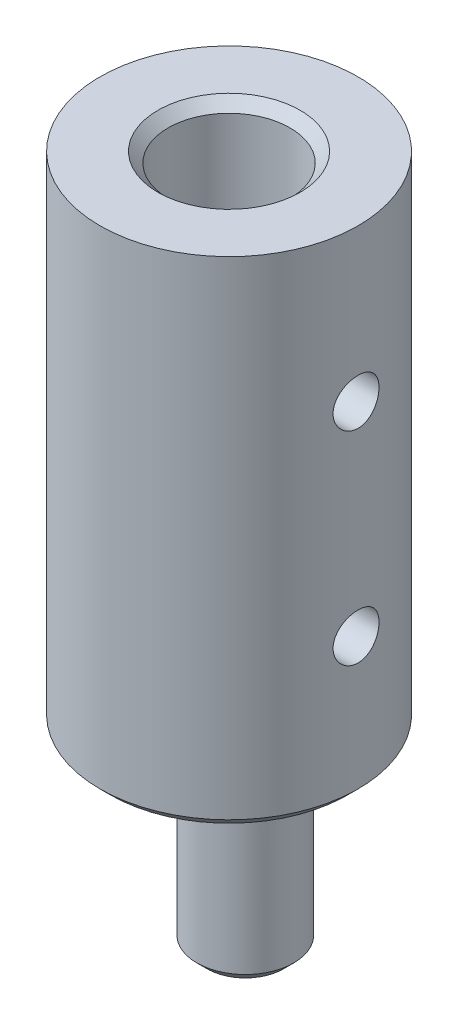
from build123d import *

# Parameters (mm, degrees)
SKETCH1_R             = 6.35
BOSS_EXTRUDE1_DEPTH   = 24.5
SKETCH2_R             = 3
CUT_EXTRUDE1_DEPTH    = 21.6
F_4_40_TAPPED_HOLE1_D = 2.2606
SKETCH5_R             = 2.38125
BOSS_EXTRUDE2_DEPTH   = 9
CHAMFER2_SIZE         = 0.5


with BuildPart() as part:
    # Sketch1 → Boss-Extrude1 (new body)
    with BuildSketch(Plane(origin=(0, 0, 0), x_dir=(1, 0, 0), z_dir=(0, 1, 0))):
        Circle(SKETCH1_R)
    extrude(amount=BOSS_EXTRUDE1_DEPTH)

    # Sketch2 → Cut-Extrude1 (cut)
    with BuildSketch(Plane(origin=(0, 24.5, 0), x_dir=(1, 0, 0), z_dir=(0, 1, 0))):
        Circle(SKETCH2_R)
    extrude(amount=-CUT_EXTRUDE1_DEPTH, mode=Mode.SUBTRACT)

    # #4-40 Tapped Hole1 (through all)
    with Locations(Plane(origin=(6.35, 0, 0), x_dir=(0, 0, -1), z_dir=(1, 0, 0))):
        with Locations((0, 17), (0, 7)):
            Hole(F_4_40_TAPPED_HOLE1_D / 2)

    # Sketch5 → Boss-Extrude2 (add)
    with BuildSketch(Plane(origin=(0, 0, 0), x_dir=(-1, 0, 0), z_dir=(0, -1, 0))):
        with Locations((-0.8, 0)):
            Circle(SKETCH5_R)
    extrude(amount=BOSS_EXTRUDE2_DEPTH)

    # Chamfer2
    chamfer2_edges = [part.edges().sort_by_distance(p)[0] for p in [
        (-6.35, 0, 0),
        (3.18125, 0, 0),
        (3.18125, -9, 0),
        (-3, 24.5, 0),
    ]]
    chamfer(chamfer2_edges, length=CHAMFER2_SIZE)


solid = part.part
